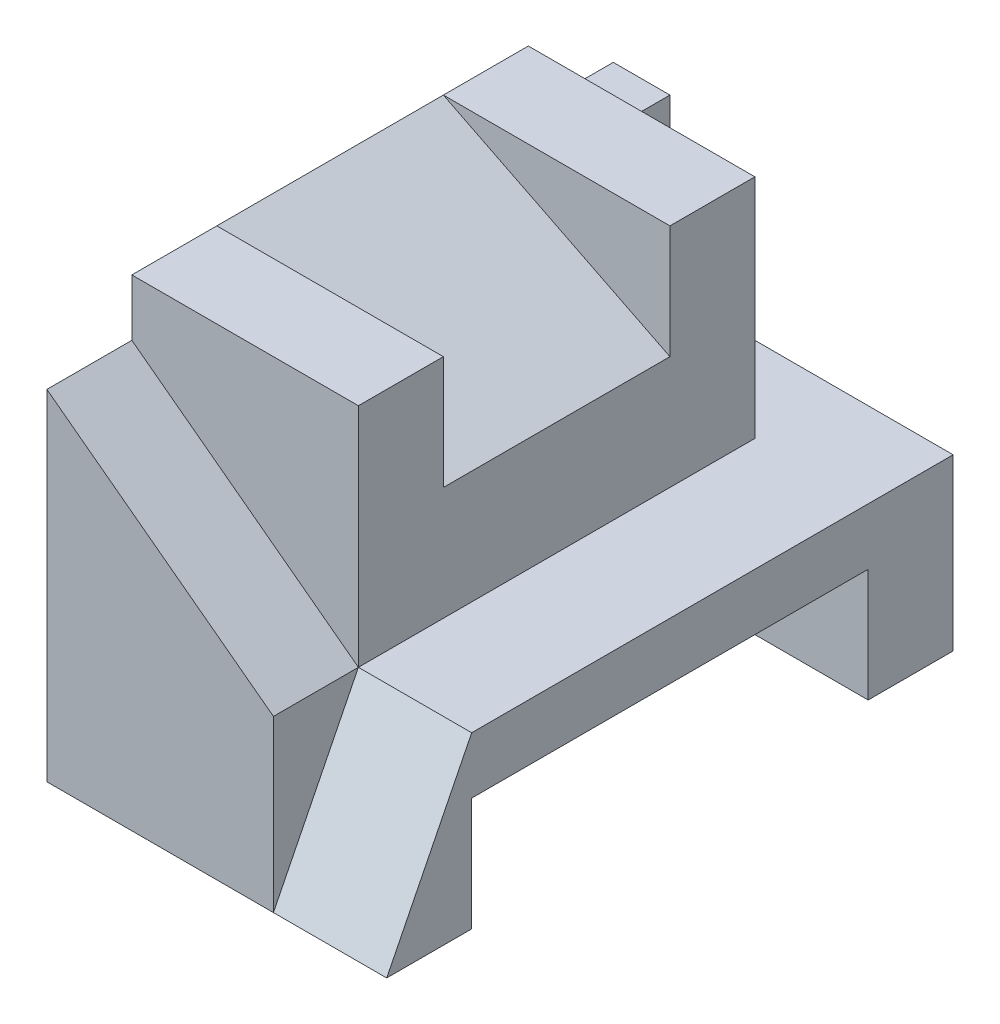
from build123d import *

# Parameters (mm, degrees)
SALIENTE_EXTRUIR1_DEPTH = 10
CORTAR_EXTRUIR1_DEPTH   = 1.5
CORTAR_EXTRUIR2_DEPTH   = 2
CORTAR_EXTRUIR3_REACH   = 8
CROQUIS5_W              = 7
CROQUIS5_H              = 2
CORTAR_EXTRUIR4_DEPTH   = 1.5
CORTAR_EXTRUIR5_DEPTH   = 2


with BuildPart() as part:
    # Croquis1 → Saliente-Extruir1 (new body)
    with BuildSketch(Plane.XY):
        Polygon((0, 0), (6, 0), (6, 3), (4, 3), (4, 7), (0, 7), align=None)
    extrude(amount=-SALIENTE_EXTRUIR1_DEPTH)

    # Croquis2 → Cortar-Extruir1 (cut)
    with BuildSketch(Plane.XY):
        Polygon((4, 3), (0, 6), (0, 7), (4, 7), align=None)
    extrude(amount=-CORTAR_EXTRUIR1_DEPTH, mode=Mode.SUBTRACT)

    # Croquis4 → Cortar-Extruir2 (cut)
    with BuildSketch(Plane(origin=(6, 0, 0), x_dir=(0, 0, -1), z_dir=(1, 0, 0))):
        Polygon((1.5, 3), (0, 0), (0, 3), align=None)
    extrude(amount=-CORTAR_EXTRUIR2_DEPTH, mode=Mode.SUBTRACT)

    # Croquis5 → Cortar-Extruir3 (cut, up to next)
    with BuildSketch(Plane(origin=(6, 0, 0), x_dir=(0, 0, -1), z_dir=(1, 0, 0)), mode=Mode.PRIVATE) as cortar_extruir3_sk1:
        with Locations((5, 1)):
            Rectangle(CROQUIS5_W, CROQUIS5_H)
    cortar_extruir3_tool1 = extrude(cortar_extruir3_sk1.sketch, amount=-CORTAR_EXTRUIR3_REACH, mode=Mode.PRIVATE) & part.part
    add(cortar_extruir3_tool1.solids().sort_by_distance((6, 1, -5))[0], mode=Mode.SUBTRACT)

    # Croquis6 → Cortar-Extruir4 (cut)
    with BuildSketch(Plane(origin=(0, 0, -10), x_dir=(-1, 0, 0), z_dir=(0, 0, -1))):
        Polygon((-4, 7), (0, 7), (0, 6), (-1, 6), (-1, 3), (-4, 3), align=None)
    extrude(amount=-CORTAR_EXTRUIR4_DEPTH, mode=Mode.SUBTRACT)

    # Croquis7 → Cortar-Extruir5 (cut, symmetric)
    with BuildSketch(Plane.XY.offset(-5)):
        Polygon((4, 5), (4, 7), (0, 7), align=None)
    extrude(amount=CORTAR_EXTRUIR5_DEPTH, both=True, mode=Mode.SUBTRACT)


solid = part.part
